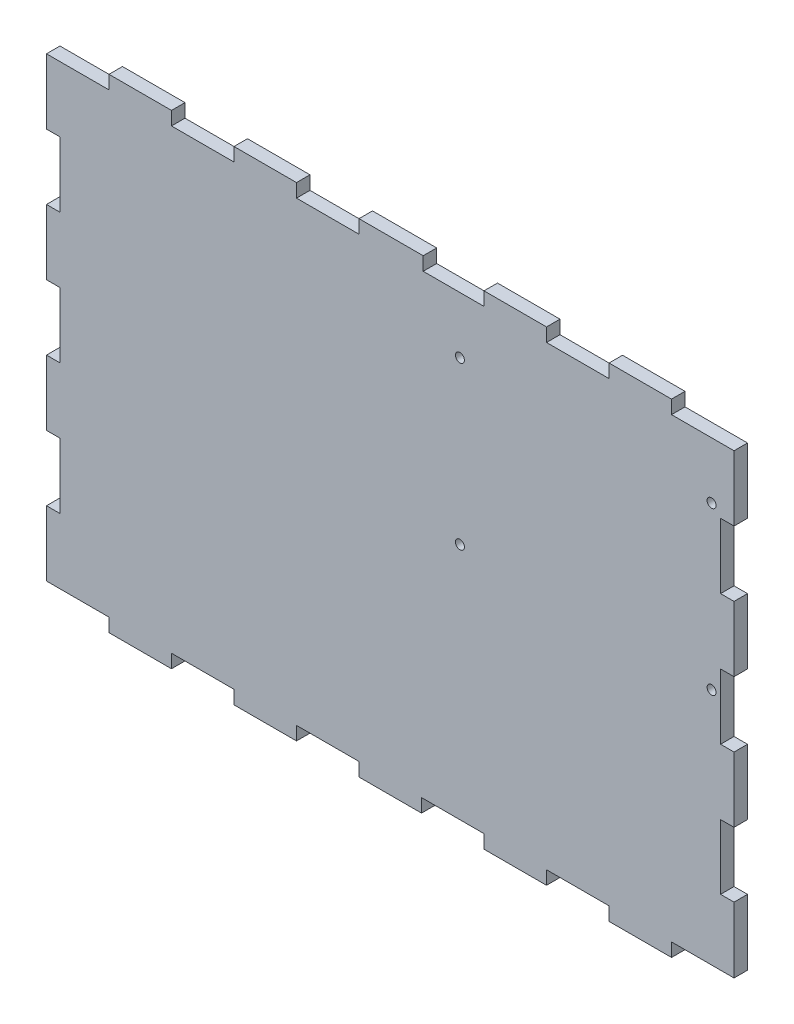
from build123d import *

# Parameters (mm, degrees)
CROQUIS1_R              = 1
SALIENTE_EXTRUIR1_DEPTH = 3


with BuildPart() as part:
    # Croquis1 → Saliente-Extruir1 (new body)
    with BuildSketch(Plane.XY):
        Polygon((-34.480909091, -156.100114598), (-48.39, -156.100114598), (-48.39, -170.615828883), (-45.39, -170.615828883), (-45.39, -185.131543169), (-48.39, -185.131543169), (-48.39, -199.647257455), (-45.39, -199.647257455), (-45.39, -214.162971741), (-48.39, -214.162971741), (-48.39, -228.678686026), (-45.39, -228.678686026), (-45.39, -243.194400312), (-48.39, -243.194400312), (-48.39, -257.710114598), (-34.480909091, -257.710114598), (-34.480909091, -260.710114598), (-20.571818182, -260.710114598), (-20.571818182, -257.710114598), (-6.662727273, -257.710114598), (-6.662727273, -260.710114598), (7.246363636, -260.710114598), (7.246363636, -257.710114598), (21.155454545, -257.710114598), (21.155454545, -260.710114598), (35.064545455, -260.710114598), (35.064545455, -257.710114598), (48.973636364, -257.710114598), (48.973636364, -260.710114598), (62.882727273, -260.710114598), (62.882727273, -257.710114598), (76.791818182, -257.710114598), (76.791818182, -260.710114598), (90.700909091, -260.710114598), (90.700909091, -257.710114598), (104.61, -257.710114598), (104.61, -243.087661526), (101.61, -243.087661526), (101.61, -228.678686026), (104.61, -228.678686026), (104.61, -214.162971741), (101.61, -214.162971741), (101.61, -199.647257455), (104.61, -199.647257455), (104.61, -185.131543169), (101.61, -185.131543169), (101.61, -170.615828883), (104.61, -170.615828883), (104.61, -156.100114598), (90.700909091, -156.100114598), (90.700909091, -153.100114598), (76.791818182, -153.100114598), (76.791818182, -156.100114598), (62.882727273, -156.100114598), (62.882727273, -153.100114598), (48.973636364, -153.100114598), (48.973636364, -156.100114598), (35.440889541, -156.100114598), (35.440889541, -153.100114598), (21.155454545, -153.100114598), (21.155454545, -156.100114598), (7.246363636, -156.100114598), (7.246363636, -153.100114598), (-6.662727273, -153.100114598), (-6.662727273, -156.100114598), (-20.571818182, -156.100114598), (-20.571818182, -153.100114598), (-34.480909091, -153.100114598), align=None)
        with Locations((99.61, -168.670114598)):
            Circle(CROQUIS1_R, mode=Mode.SUBTRACT)
        with Locations((99.61, -204.670114598)):
            Circle(CROQUIS1_R, mode=Mode.SUBTRACT)
        with Locations((43.61, -168.670114598)):
            Circle(CROQUIS1_R, mode=Mode.SUBTRACT)
        with Locations((43.61, -204.670114598)):
            Circle(CROQUIS1_R, mode=Mode.SUBTRACT)
    extrude(amount=SALIENTE_EXTRUIR1_DEPTH)


solid = part.part
